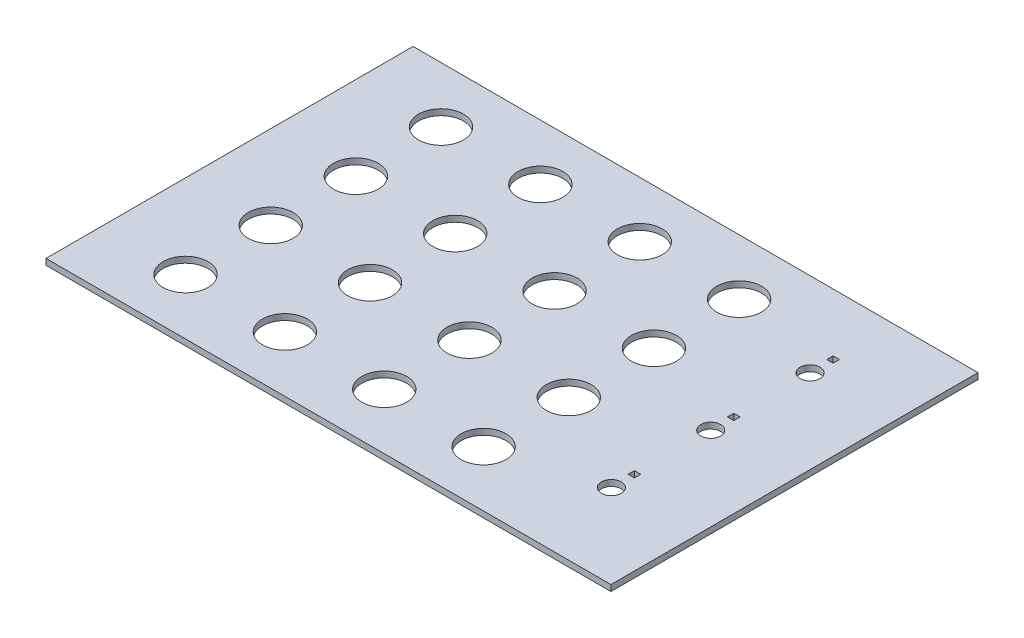
from build123d import *

# Parameters (mm, degrees)
SKETCH1_W           = 199
SKETCH1_H           = 129.3
SKETCH1_R           = 7.9
SKETCH1_R_2         = 3.5
SKETCH1_W_2         = 2.25
SKETCH1_H_2         = 2.25
BOSS_EXTRUDE1_DEPTH = 2.13


with BuildPart() as part:
    # Sketch1 → Boss-Extrude1 (new body)
    with BuildSketch(Plane(origin=(0, 0, 0), x_dir=(1, 0, 0), z_dir=(0, 1, 0))):
        Rectangle(SKETCH1_W, SKETCH1_H)
        with Locations((-70, 45)):
            Circle(SKETCH1_R, mode=Mode.SUBTRACT)
        with Locations((-35, 45)):
            Circle(SKETCH1_R, mode=Mode.SUBTRACT)
        with Locations((0, 45)):
            Circle(SKETCH1_R, mode=Mode.SUBTRACT)
        with Locations((35, 45)):
            Circle(SKETCH1_R, mode=Mode.SUBTRACT)
        with Locations((-35, 15)):
            Circle(SKETCH1_R, mode=Mode.SUBTRACT)
        with Locations((0, 15)):
            Circle(SKETCH1_R, mode=Mode.SUBTRACT)
        with Locations((35, 15)):
            Circle(SKETCH1_R, mode=Mode.SUBTRACT)
        with Locations((-35, -15)):
            Circle(SKETCH1_R, mode=Mode.SUBTRACT)
        with Locations((0, -15)):
            Circle(SKETCH1_R, mode=Mode.SUBTRACT)
        with Locations((35, -15)):
            Circle(SKETCH1_R, mode=Mode.SUBTRACT)
        with Locations((-35, -45)):
            Circle(SKETCH1_R, mode=Mode.SUBTRACT)
        with Locations((0, -45)):
            Circle(SKETCH1_R, mode=Mode.SUBTRACT)
        with Locations((35, -45)):
            Circle(SKETCH1_R, mode=Mode.SUBTRACT)
        with Locations((-70, 15)):
            Circle(SKETCH1_R, mode=Mode.SUBTRACT)
        with Locations((-70, -15)):
            Circle(SKETCH1_R, mode=Mode.SUBTRACT)
        with Locations((-70, -45)):
            Circle(SKETCH1_R, mode=Mode.SUBTRACT)
        with Locations((70, 35)):
            Circle(SKETCH1_R_2, mode=Mode.SUBTRACT)
        with Locations((70, 0)):
            Circle(SKETCH1_R_2, mode=Mode.SUBTRACT)
        with Locations((70, -35)):
            Circle(SKETCH1_R_2, mode=Mode.SUBTRACT)
        with Locations((70, 43.125)):
            Rectangle(SKETCH1_W_2, SKETCH1_H_2, mode=Mode.SUBTRACT)
        with Locations((70, 8.125)):
            Rectangle(SKETCH1_W_2, SKETCH1_H_2, mode=Mode.SUBTRACT)
        with Locations((70, -26.875)):
            Rectangle(SKETCH1_W_2, SKETCH1_H_2, mode=Mode.SUBTRACT)
    extrude(amount=BOSS_EXTRUDE1_DEPTH)


solid = part.part
